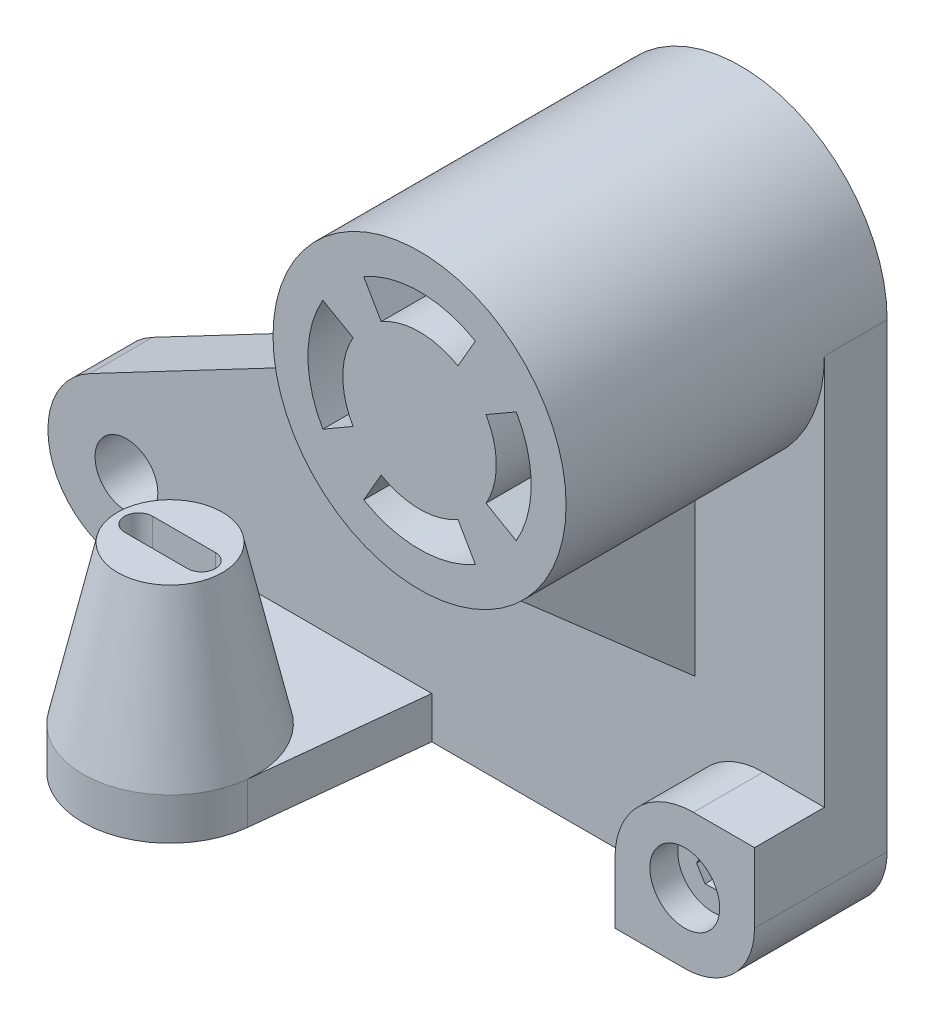
from build123d import *

# Parameters (mm, degrees)
IZIM1_R                     = 9
Y_KSEKLIK_EKSTR_ZYON1_DEPTH = 18
IZIM2_R                     = 42
Y_KSEKLIK_EKSTR_ZYON2_DEPTH = 92
Y_KSEKLIK_EKSTR_ZYON3_DEPTH = 20
KES_EKSTR_ZYON1_DEPTH       = 60
KES_EKSTR_ZYON2_DEPTH       = 108
FEDER1_REACH                = 282.501
IZIM6_WALL_W                = 648.043161204
IZIM6_WALL_H                = 10
Y_KSEKLIK_EKSTR_ZYON4_DEPTH = 12
IZIM9_R                     = 25
IZIM8_R                     = 15
KES_EKSTR_ZYON3_DEPTH       = 65
IZIM11_R                    = 10
KES_EKSTR_ZYON4_DEPTH       = 8


with BuildPart() as part:
    # Çizim1 → Yükseklik-Ekstrüzyon1 (new body)
    with BuildSketch(Plane.XY):
        with BuildLine():
            Line((-32.411549897, 0), (147.588450103, 0))
            ThreePointArc((147.588450103, 0), (161.730585727, 5.857864376), (167.588450103, 20))
            Line((167.588450103, 20), (167.588450103, 152))
            ThreePointArc((167.588450103, 152), (125.588450103, 110), (83.588450103, 152))
            Line((83.588450103, 152), (83.588450103, 106.718465751))
            ThreePointArc((83.588450103, 106.718465751), (76.934365543, 90.65408456), (60.869984352, 84))
            Line((60.869984352, 84), (38.285308022, 84))
            ThreePointArc((38.285308022, 84), (35.198315251, 83.226334615), (32.273122012, 81.972808782))
            Line((32.273122012, 81.972808782), (-42.891293999, 42.41042349))
            ThreePointArc((-42.891293999, 42.41042349), (-54.25456398, 17.102525059), (-32.411549897, 0))
        make_face()
        with Locations((48.588450103, 64)):
            Circle(IZIM1_R, mode=Mode.SUBTRACT)
        with Locations((-32.411549897, 22.5)):
            Circle(IZIM1_R, mode=Mode.SUBTRACT)
    extrude(amount=Y_KSEKLIK_EKSTR_ZYON1_DEPTH)

    # Çizim2 → Yükseklik-Ekstrüzyon2 (add)
    with BuildSketch(Plane.XY):
        with Locations((125.588450103, 152)):
            Circle(IZIM2_R)
    extrude(amount=Y_KSEKLIK_EKSTR_ZYON2_DEPTH)

    # Çizim3 → Yükseklik-Ekstrüzyon3 (add)
    with BuildSketch(Plane.XY.offset(18)):
        with BuildLine():
            Line((127.588450103, 0), (127.588450103, 17.51012232))
            ThreePointArc((127.588450103, 17.51012232), (134.175582768, 33.412867336), (150.078327783, 40))
            Line((150.078327783, 40), (167.588450103, 40))
            Line((167.588450103, 40), (167.588450103, 20))
            ThreePointArc((167.588450103, 20), (161.730585727, 5.857864376), (147.588450103, 0))
            Line((147.588450103, 0), (127.588450103, 0))
        make_face()
    extrude(amount=Y_KSEKLIK_EKSTR_ZYON3_DEPTH)

    # Çizim4 → Kes-Ekstrüzyon1 (cut)
    with BuildSketch(Plane.XY.offset(38)):
        Polygon((145.407352826, 15.928618416), (150.023821345, 16.075423558), (152.204918622, 20.146805142), (149.76954738, 24.071381584), (145.153078862, 23.924576442), (142.971981585, 19.853194858), align=None)
    extrude(amount=-KES_EKSTR_ZYON1_DEPTH, mode=Mode.SUBTRACT)

    # Çizim5 → Kes-Ekstrüzyon2 (cut)
    with BuildSketch(Plane.XY.offset(92)):
        with BuildLine():
            Line((136.588450103, 171.052558883), (141.588450103, 179.712812921))
            ThreePointArc((141.588450103, 179.712812921), (125.588450103, 184), (109.588450103, 179.712812921))
            Line((109.588450103, 179.712812921), (114.588450103, 171.052558883))
            ThreePointArc((114.588450103, 171.052558883), (125.588450103, 174), (136.588450103, 171.052558883))
        make_face()
        with BuildLine():
            Line((144.641008987, 141), (153.301263025, 136))
            ThreePointArc((153.301263025, 136), (157.588450103, 152), (153.301263025, 168))
            Line((153.301263025, 168), (144.641008987, 163))
            ThreePointArc((144.641008987, 163), (147.588450103, 152), (144.641008987, 141))
        make_face()
        with BuildLine():
            Line((114.588450103, 132.947441117), (109.588450103, 124.287187079))
            ThreePointArc((109.588450103, 124.287187079), (125.588450103, 120), (141.588450103, 124.287187079))
            Line((141.588450103, 124.287187079), (136.588450103, 132.947441117))
            ThreePointArc((136.588450103, 132.947441117), (125.588450103, 130), (114.588450103, 132.947441117))
        make_face()
        with BuildLine():
            Line((106.53589122, 163), (97.875637182, 168))
            ThreePointArc((97.875637182, 168), (93.588450103, 152), (97.875637182, 136))
            Line((97.875637182, 136), (106.53589122, 141))
            ThreePointArc((106.53589122, 141), (103.588450103, 152), (106.53589122, 163))
        make_face()
    extrude(amount=-KES_EKSTR_ZYON2_DEPTH, mode=Mode.SUBTRACT)

    # Çizim6 wall → Feder1 (add, up to next)
    with BuildSketch(Plane(origin=(125.59, 82, 50), x_dir=(0, -0.658504607869, -0.752576694707), z_dir=(0, 0.752576694707, -0.658504607869)), mode=Mode.PRIVATE) as feder1_sk1:
        Rectangle(IZIM6_WALL_W, IZIM6_WALL_H)
    feder1_tool1 = extrude(feder1_sk1.sketch, amount=FEDER1_REACH, mode=Mode.PRIVATE) - part.part
    add(feder1_tool1.solids().sort_by_distance((125.59, 82, 50))[0])

    # Çizim7 → Yükseklik-Ekstrüzyon4 (add)
    with BuildSketch(Plane(origin=(0, 0, 0), x_dir=(1, 0, 0), z_dir=(0, 1, 0))):
        with BuildLine():
            Line((-4.911549897, -18), (0.232687834, -65.681619291))
            ThreePointArc((0.232687834, -65.681619291), (25.088450103, -88), (49.944212373, -65.681619291))
            Line((49.944212373, -65.681619291), (55.088450103, -18))
            Line((55.088450103, -18), (-4.911549897, -18))
        make_face()
    extrude(amount=Y_KSEKLIK_EKSTR_ZYON4_DEPTH)

    # Çizim9 → Loft1 section 0
    with BuildSketch(Plane(origin=(0, 12, 0), x_dir=(1, 0, 0), z_dir=(0, 1, 0))):
        with Locations((25.088450103, -63)):
            Circle(IZIM9_R)
    # Çizim8 → Loft1 section 1
    with BuildSketch(Plane(origin=(0, 57, 0), x_dir=(1, 0, 0), z_dir=(0, 1, 0))):
        with Locations((25.088450103, -63)):
            Circle(IZIM8_R)
    loft()

    # Çizim10 → Kes-Ekstrüzyon3 (cut)
    with BuildSketch(Plane(origin=(0, 57, 0), x_dir=(1, 0, 0), z_dir=(0, 1, 0))):
        with BuildLine():
            Line((16.088450103, -59), (34.088450103, -59))
            ThreePointArc((34.088450103, -59), (38.088450103, -63), (34.088450103, -67))
            Line((34.088450103, -67), (16.088450103, -67))
            ThreePointArc((16.088450103, -67), (12.088450103, -63), (16.088450103, -59))
        make_face()
    extrude(amount=-KES_EKSTR_ZYON3_DEPTH, mode=Mode.SUBTRACT)

    # Çizim11 → Kes-Ekstrüzyon4 (cut)
    with BuildSketch(Plane.XY.offset(38)):
        with Locations((147.588450103, 20)):
            Circle(IZIM11_R)
    extrude(amount=-KES_EKSTR_ZYON4_DEPTH, mode=Mode.SUBTRACT)


solid = part.part
